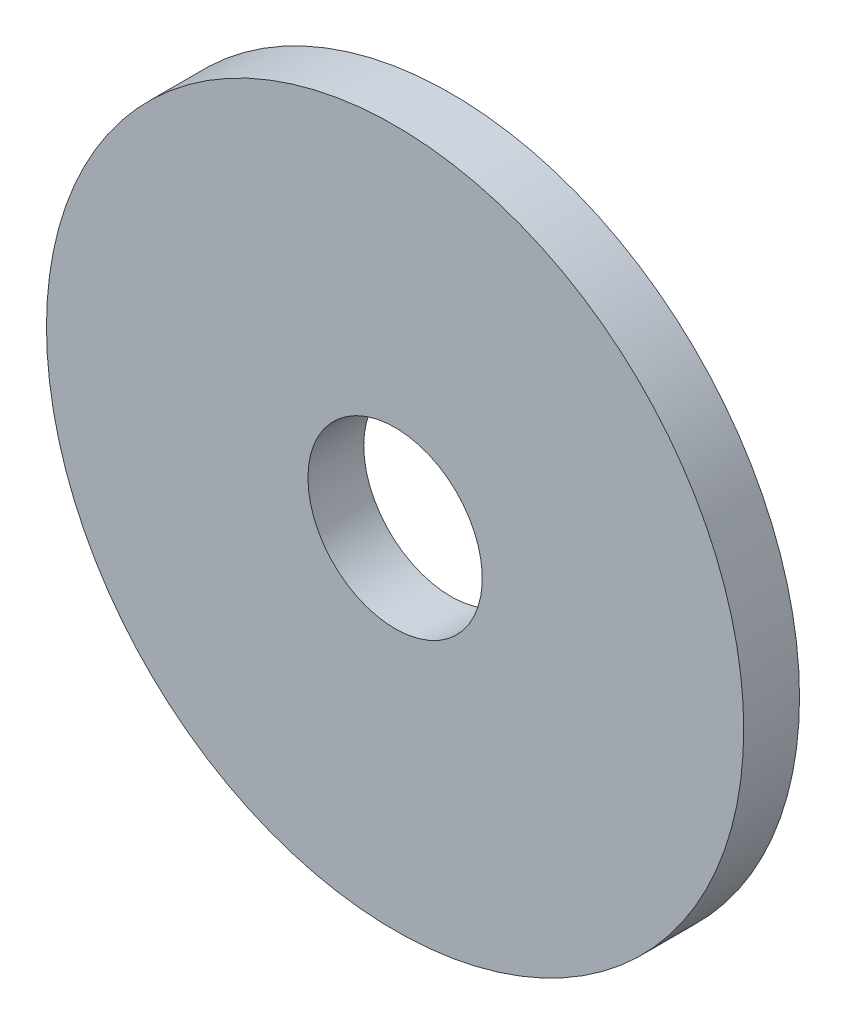
from build123d import *

# Parameters (mm, degrees)
ESQUISSE1_R             = 12.5
BOSS_EXTRU_1_DEPTH      = 2
ESQUISSE2_R             = 3.125
ENL_V_MAT_EXTRU_1_DEPTH = 3


with BuildPart() as part:
    # Esquisse1 → Boss.-Extru.1 (new body)
    with BuildSketch(Plane.XY):
        Circle(ESQUISSE1_R)
    extrude(amount=BOSS_EXTRU_1_DEPTH)

    # Esquisse2 → Enlèv. mat.-Extru.1 (cut, through all)
    with BuildSketch(Plane(origin=(0, 0, 0), x_dir=(-1, 0, 0), z_dir=(0, 0, -1))):
        Circle(ESQUISSE2_R)
    extrude(amount=-ENL_V_MAT_EXTRU_1_DEPTH, mode=Mode.SUBTRACT)


solid = part.part
